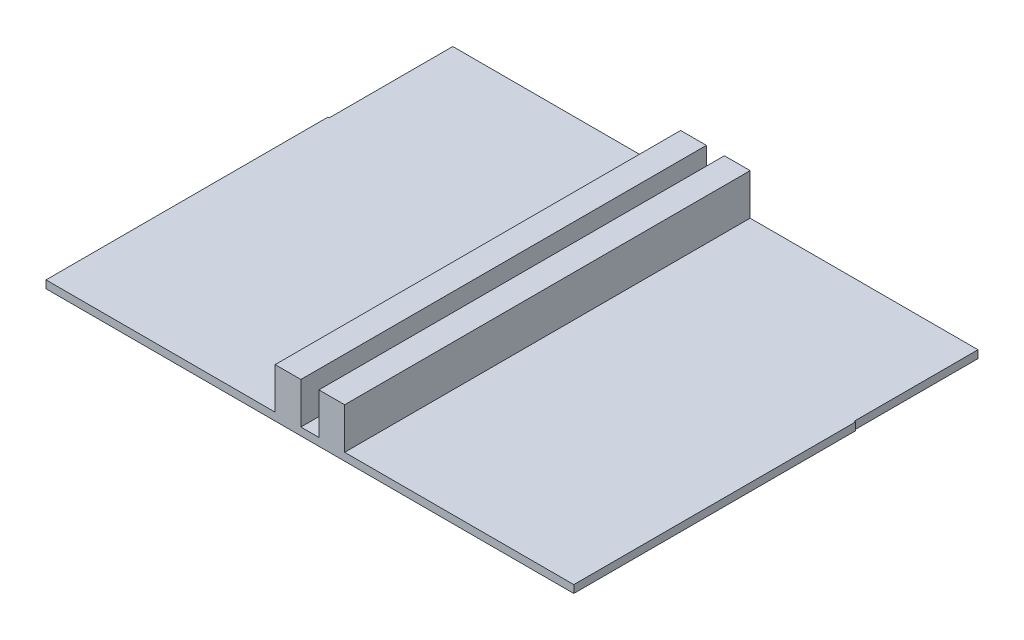
from build123d import *

# Parameters (mm, degrees)
BOSS_EXTRUDE1_DEPTH = 0.3
SKETCH2_W           = 1
SKETCH2_H           = 15.75
BOSS_EXTRUDE2_DEPTH = 1.6
SKETCH1_3_W         = 0.25
SKETCH1_3_H         = 10.95
CUT_EXTRUDE2_DEPTH  = 10


with BuildPart() as part:
    # Sketch1 → Boss-Extrude1 (new body)
    with BuildSketch(Plane(origin=(0, 0, 0), x_dir=(1, 0, 0), z_dir=(0, 1, 0))):
        Polygon((-10.5, 10.95), (-10.5, 0), (10.5, 0), (10.5, 10.95), (10.2, 10.95), (10.2, 15.75), (0.35, 15.75), (0.35, 11), (-0.35, 11), (-0.35, 15.75), (-10.2, 15.75), (-10.2, 10.95), align=None)
    extrude(amount=BOSS_EXTRUDE1_DEPTH)

    # Sketch2 → Boss-Extrude2 (add)
    with BuildSketch(Plane(origin=(0, 0.3, 0), x_dir=(1, 0, 0), z_dir=(0, 1, 0))):
        with Locations((-0.85, 7.875)):
            Rectangle(SKETCH2_W, SKETCH2_H)
        with Locations((0.85, 7.875)):
            Rectangle(SKETCH2_W, SKETCH2_H)
    extrude(amount=BOSS_EXTRUDE2_DEPTH)

    # Sketch1_3 → Cut-Extrude2 (cut)
    with BuildSketch(Plane(origin=(0, 0, 0), x_dir=(1, 0, 0), z_dir=(0, 1, 0))):
        with Locations((-10.375, 5.475)):
            Rectangle(SKETCH1_3_W, SKETCH1_3_H)
        with Locations((10.375, 5.475)):
            Rectangle(SKETCH1_3_W, SKETCH1_3_H)
    extrude(amount=CUT_EXTRUDE2_DEPTH, mode=Mode.SUBTRACT)


solid = part.part
